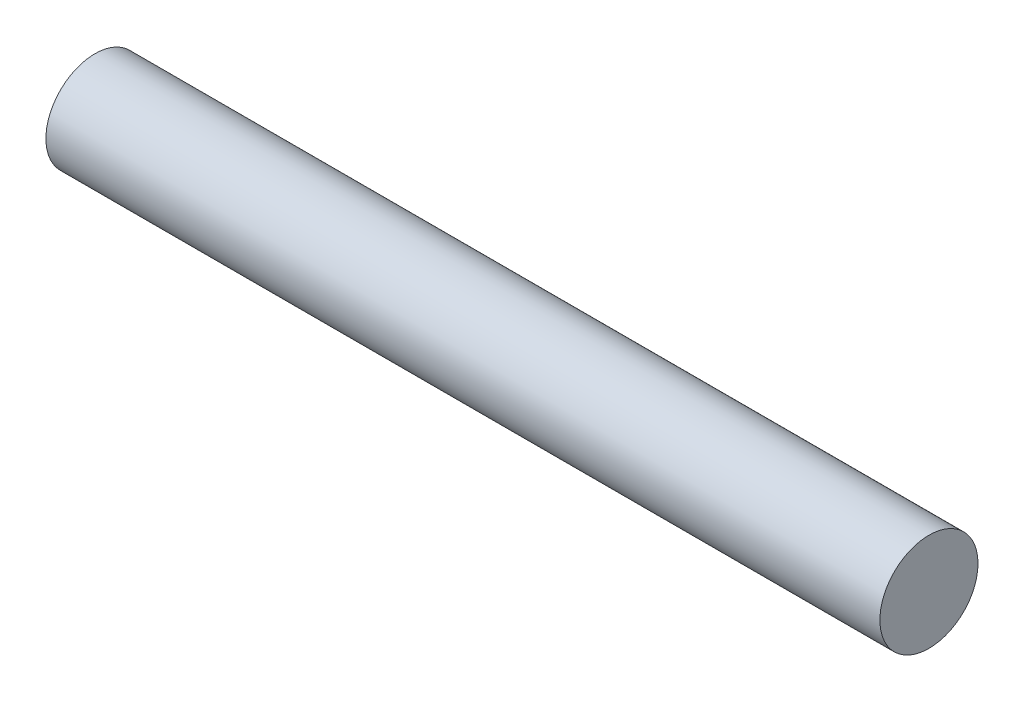
from build123d import *

# Parameters (mm, degrees)
SKETCH1_R           = 10
BOSS_EXTRUDE1_DEPTH = 85


with BuildPart() as part:
    # Sketch1 → Boss-Extrude1 (new body, symmetric)
    with BuildSketch(Plane(origin=(0, 0, 0), x_dir=(0, 0, -1), z_dir=(1, 0, 0))):
        with Locations((-11.638767161, 3.314158094)):
            Circle(SKETCH1_R)
    extrude(amount=BOSS_EXTRUDE1_DEPTH, both=True)


solid = part.part
